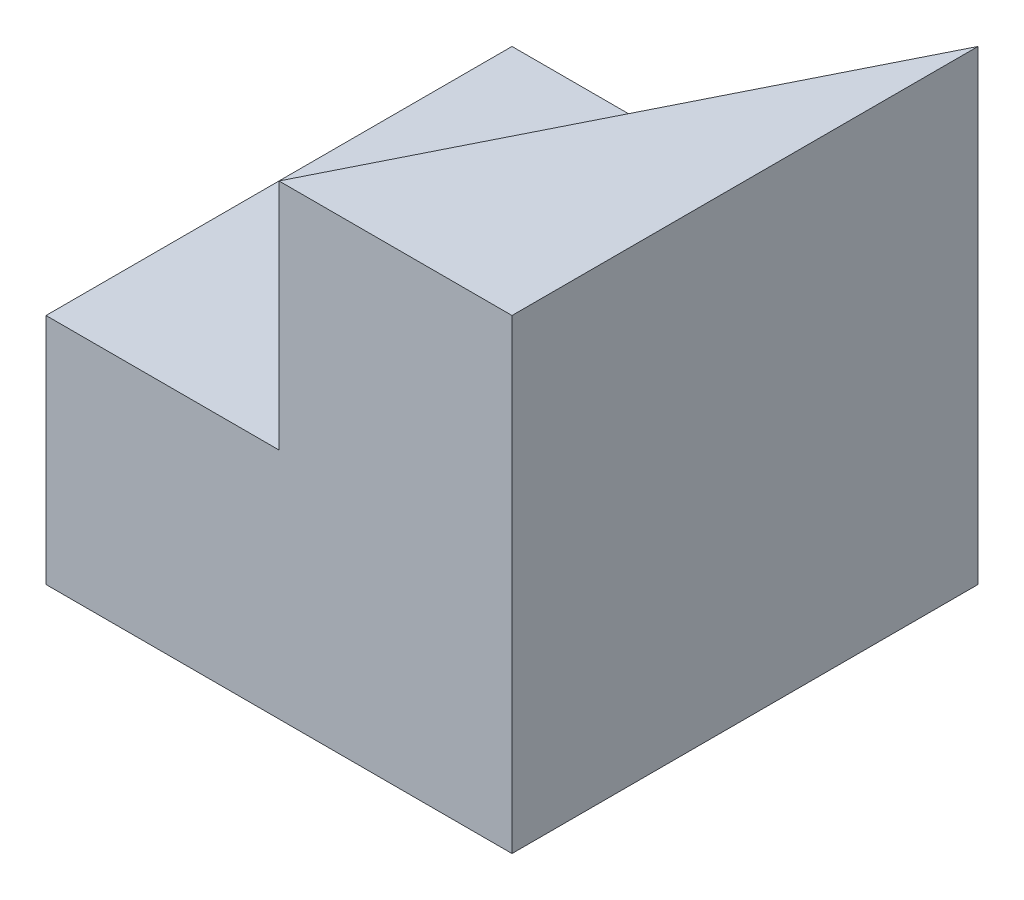
from build123d import *

# Parameters (mm, degrees)
SKETCH1_W           = 40
SKETCH1_H           = 40
BOSS_EXTRUDE1_DEPTH = 40
SKETCH2_W           = 20
SKETCH2_H           = 20
CUT_EXTRUDE1_DEPTH  = 40
CUT_EXTRUDE2_DEPTH  = 20


with BuildPart() as part:
    # Sketch1 → Boss-Extrude1 (new body)
    with BuildSketch(Plane.XY):
        with Locations((20, 20)):
            Rectangle(SKETCH1_W, SKETCH1_H)
    extrude(amount=BOSS_EXTRUDE1_DEPTH)

    # Sketch2 → Cut-Extrude1 (cut)
    with BuildSketch(Plane.XY.offset(40)):
        with Locations((10, 30)):
            Rectangle(SKETCH2_W, SKETCH2_H)
    extrude(amount=-CUT_EXTRUDE1_DEPTH, mode=Mode.SUBTRACT)

    # Sketch3 → Cut-Extrude2 (cut)
    with BuildSketch(Plane(origin=(0, 40, 0), x_dir=(1, 0, 0), z_dir=(0, 1, 0))):
        Polygon((20, -40), (40, 0), (20, 0), align=None)
    extrude(amount=-CUT_EXTRUDE2_DEPTH, mode=Mode.SUBTRACT)


solid = part.part
